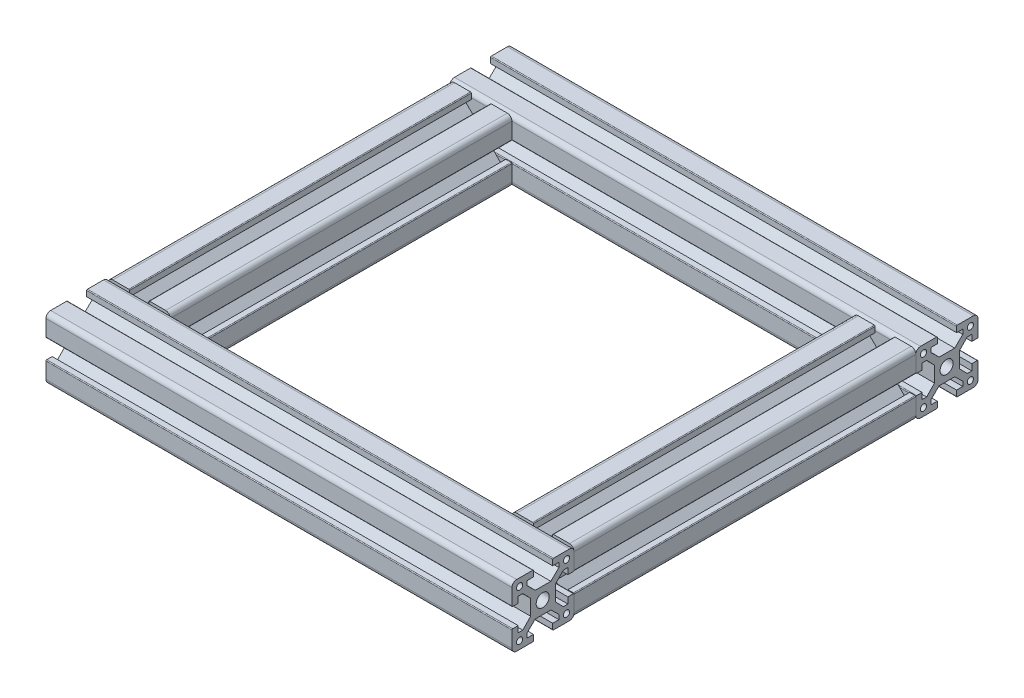
from build123d import *

# Parameters (mm, degrees)
SKETCH11_R                = 1
SKETCH11_R_2              = 2.1
XA_XA_2020T_1_DEPTH       = 140.110875788
XA_XA_2020T_1_DEPTH_BACK  = 9.889124212
SKETCH11_ON_SEGMENT_2_R   = 1
SKETCH11_ON_SEGMENT_2_R_2 = 2.1
XA_XA_2020T_1_2_DEPTH     = 150
SKETCH11_ON_SEGMENT_3_R   = 1
SKETCH11_ON_SEGMENT_3_R_2 = 2.1
XA_XA_2020T_1_3_DEPTH     = 132
SKETCH11_ON_SEGMENT_4_R   = 1
SKETCH11_ON_SEGMENT_4_R_2 = 2.1
XA_XA_2020T_1_4_DEPTH     = 132


with BuildPart() as part:
    # Sketch11 → Xa XA-2020T(1) (new, two sides)
    with BuildSketch(Plane(origin=(-46.28, 0, -40.646666667), x_dir=(0, 0, -1), z_dir=(1, 0, 0))) as xa_xa_2020t_1_sk:
        with BuildLine():
            Line((-9.889124212, 8.439448346), (-9.889124212, 3.289448346))
            ThreePointArc((-9.889124212, 3.289448346), (-9.815900907, 3.112671651), (-9.639124212, 3.039448346))
            Line((-9.639124212, 3.039448346), (-7.889124212, 3.039448346))
            Line((-7.889124212, 3.039448346), (-7.889124212, 5.039448346))
            Line((-7.889124212, 5.039448346), (-6.41690199, 5.039448346))
            Line((-6.41690199, 5.039448346), (-3.889124212, 2.439448346))
            Line((-3.889124212, 2.439448346), (-3.889124212, -2.560551654))
            Line((-3.889124212, -2.560551654), (-6.41690199, -5.160551654))
            Line((-6.41690199, -5.160551654), (-7.889124212, -5.160551654))
            Line((-7.889124212, -5.160551654), (-7.889124212, -3.160551654))
            Line((-7.889124212, -3.160551654), (-9.639124212, -3.160551654))
            ThreePointArc((-9.639124212, -3.160551654), (-9.815900907, -3.233774958), (-9.889124212, -3.410551654))
            Line((-9.889124212, -3.410551654), (-9.889124212, -8.560551654))
            ThreePointArc((-9.889124212, -8.560551654), (-9.449784384, -9.621211825), (-8.389124212, -10.060551654))
            Line((-8.389124212, -10.060551654), (-3.239124212, -10.060551654))
            ThreePointArc((-3.239124212, -10.060551654), (-3.062347516, -9.987328349), (-2.989124212, -9.810551654))
            Line((-2.989124212, -9.810551654), (-2.989124212, -8.060551654))
            Line((-2.989124212, -8.060551654), (-4.989124212, -8.060551654))
            Line((-4.989124212, -8.060551654), (-4.989124212, -6.588329431))
            Line((-4.989124212, -6.588329431), (-2.389124212, -4.060551654))
            Line((-2.389124212, -4.060551654), (2.610875788, -4.060551654))
            Line((2.610875788, -4.060551654), (5.210875788, -6.588329431))
            Line((5.210875788, -6.588329431), (5.210875788, -8.060551654))
            Line((5.210875788, -8.060551654), (3.210875788, -8.060551654))
            Line((3.210875788, -8.060551654), (3.210875788, -9.810551654))
            ThreePointArc((3.210875788, -9.810551654), (3.284099093, -9.987328349), (3.460875788, -10.060551654))
            Line((3.460875788, -10.060551654), (8.610875788, -10.060551654))
            ThreePointArc((8.610875788, -10.060551654), (9.67153596, -9.621211825), (10.110875788, -8.560551654))
            Line((10.110875788, -8.560551654), (10.110875788, -3.410551654))
            ThreePointArc((10.110875788, -3.410551654), (10.037652484, -3.233774958), (9.860875788, -3.160551654))
            Line((9.860875788, -3.160551654), (8.110875788, -3.160551654))
            Line((8.110875788, -3.160551654), (8.110875788, -5.160551654))
            Line((8.110875788, -5.160551654), (6.638653566, -5.160551654))
            Line((6.638653566, -5.160551654), (4.110875788, -2.560551654))
            Line((4.110875788, -2.560551654), (4.110875788, 2.439448346))
            Line((4.110875788, 2.439448346), (6.638653566, 5.039448346))
            Line((6.638653566, 5.039448346), (8.110875788, 5.039448346))
            Line((8.110875788, 5.039448346), (8.110875788, 3.039448346))
            Line((8.110875788, 3.039448346), (9.860875788, 3.039448346))
            ThreePointArc((9.860875788, 3.039448346), (10.037652484, 3.112671651), (10.110875788, 3.289448346))
            Line((10.110875788, 3.289448346), (10.110875788, 8.439448346))
            ThreePointArc((10.110875788, 8.439448346), (9.67153596, 9.500108518), (8.610875788, 9.939448346))
            Line((8.610875788, 9.939448346), (3.460875788, 9.939448346))
            ThreePointArc((3.460875788, 9.939448346), (3.284099093, 9.866225042), (3.210875788, 9.689448346))
            Line((3.210875788, 9.689448346), (3.210875788, 7.939448346))
            Line((3.210875788, 7.939448346), (5.210875788, 7.939448346))
            Line((5.210875788, 7.939448346), (5.210875788, 6.467226124))
            Line((5.210875788, 6.467226124), (2.610875788, 3.939448346))
            Line((2.610875788, 3.939448346), (-2.389124212, 3.939448346))
            Line((-2.389124212, 3.939448346), (-4.989124212, 6.467226124))
            Line((-4.989124212, 6.467226124), (-4.989124212, 7.939448346))
            Line((-4.989124212, 7.939448346), (-2.989124212, 7.939448346))
            Line((-2.989124212, 7.939448346), (-2.989124212, 9.689448346))
            ThreePointArc((-2.989124212, 9.689448346), (-3.062347516, 9.866225042), (-3.239124212, 9.939448346))
            Line((-3.239124212, 9.939448346), (-8.389124212, 9.939448346))
            ThreePointArc((-8.389124212, 9.939448346), (-9.449784384, 9.500108518), (-9.889124212, 8.439448346))
        make_face()
        with Locations((-7.439124212, 7.489448346)):
            Circle(SKETCH11_R, mode=Mode.SUBTRACT)
        with Locations((7.660875788, 7.489448346)):
            Circle(SKETCH11_R, mode=Mode.SUBTRACT)
        with Locations((-7.439124212, -7.610551654)):
            Circle(SKETCH11_R, mode=Mode.SUBTRACT)
        with Locations((7.660875788, -7.610551654)):
            Circle(SKETCH11_R, mode=Mode.SUBTRACT)
        Circle(SKETCH11_R_2, mode=Mode.SUBTRACT)
    extrude(amount=XA_XA_2020T_1_DEPTH)
    extrude(xa_xa_2020t_1_sk.sketch, amount=-XA_XA_2020T_1_DEPTH_BACK)


with BuildPart() as body_2:
    # Sketch11 on segment 2 (carried to segment 2) → Xa XA-2020T_1 2 (new body)
    with BuildSketch(Plane(origin=(-56.169124212, 0, 89.353333333), x_dir=(0, 0, -1), z_dir=(1, 0, 0))):
        with BuildLine():
            Line((-9.889124212, 8.439448346), (-9.889124212, 3.289448346))
            ThreePointArc((-9.889124212, 3.289448346), (-9.815900907, 3.112671651), (-9.639124212, 3.039448346))
            Line((-9.639124212, 3.039448346), (-7.889124212, 3.039448346))
            Line((-7.889124212, 3.039448346), (-7.889124212, 5.039448346))
            Line((-7.889124212, 5.039448346), (-6.41690199, 5.039448346))
            Line((-6.41690199, 5.039448346), (-3.889124212, 2.439448346))
            Line((-3.889124212, 2.439448346), (-3.889124212, -2.560551654))
            Line((-3.889124212, -2.560551654), (-6.41690199, -5.160551654))
            Line((-6.41690199, -5.160551654), (-7.889124212, -5.160551654))
            Line((-7.889124212, -5.160551654), (-7.889124212, -3.160551654))
            Line((-7.889124212, -3.160551654), (-9.639124212, -3.160551654))
            ThreePointArc((-9.639124212, -3.160551654), (-9.815900907, -3.233774958), (-9.889124212, -3.410551654))
            Line((-9.889124212, -3.410551654), (-9.889124212, -8.560551654))
            ThreePointArc((-9.889124212, -8.560551654), (-9.449784384, -9.621211825), (-8.389124212, -10.060551654))
            Line((-8.389124212, -10.060551654), (-3.239124212, -10.060551654))
            ThreePointArc((-3.239124212, -10.060551654), (-3.062347516, -9.987328349), (-2.989124212, -9.810551654))
            Line((-2.989124212, -9.810551654), (-2.989124212, -8.060551654))
            Line((-2.989124212, -8.060551654), (-4.989124212, -8.060551654))
            Line((-4.989124212, -8.060551654), (-4.989124212, -6.588329431))
            Line((-4.989124212, -6.588329431), (-2.389124212, -4.060551654))
            Line((-2.389124212, -4.060551654), (2.610875788, -4.060551654))
            Line((2.610875788, -4.060551654), (5.210875788, -6.588329431))
            Line((5.210875788, -6.588329431), (5.210875788, -8.060551654))
            Line((5.210875788, -8.060551654), (3.210875788, -8.060551654))
            Line((3.210875788, -8.060551654), (3.210875788, -9.810551654))
            ThreePointArc((3.210875788, -9.810551654), (3.284099093, -9.987328349), (3.460875788, -10.060551654))
            Line((3.460875788, -10.060551654), (8.610875788, -10.060551654))
            ThreePointArc((8.610875788, -10.060551654), (9.67153596, -9.621211825), (10.110875788, -8.560551654))
            Line((10.110875788, -8.560551654), (10.110875788, -3.410551654))
            ThreePointArc((10.110875788, -3.410551654), (10.037652484, -3.233774958), (9.860875788, -3.160551654))
            Line((9.860875788, -3.160551654), (8.110875788, -3.160551654))
            Line((8.110875788, -3.160551654), (8.110875788, -5.160551654))
            Line((8.110875788, -5.160551654), (6.638653566, -5.160551654))
            Line((6.638653566, -5.160551654), (4.110875788, -2.560551654))
            Line((4.110875788, -2.560551654), (4.110875788, 2.439448346))
            Line((4.110875788, 2.439448346), (6.638653566, 5.039448346))
            Line((6.638653566, 5.039448346), (8.110875788, 5.039448346))
            Line((8.110875788, 5.039448346), (8.110875788, 3.039448346))
            Line((8.110875788, 3.039448346), (9.860875788, 3.039448346))
            ThreePointArc((9.860875788, 3.039448346), (10.037652484, 3.112671651), (10.110875788, 3.289448346))
            Line((10.110875788, 3.289448346), (10.110875788, 8.439448346))
            ThreePointArc((10.110875788, 8.439448346), (9.67153596, 9.500108518), (8.610875788, 9.939448346))
            Line((8.610875788, 9.939448346), (3.460875788, 9.939448346))
            ThreePointArc((3.460875788, 9.939448346), (3.284099093, 9.866225042), (3.210875788, 9.689448346))
            Line((3.210875788, 9.689448346), (3.210875788, 7.939448346))
            Line((3.210875788, 7.939448346), (5.210875788, 7.939448346))
            Line((5.210875788, 7.939448346), (5.210875788, 6.467226124))
            Line((5.210875788, 6.467226124), (2.610875788, 3.939448346))
            Line((2.610875788, 3.939448346), (-2.389124212, 3.939448346))
            Line((-2.389124212, 3.939448346), (-4.989124212, 6.467226124))
            Line((-4.989124212, 6.467226124), (-4.989124212, 7.939448346))
            Line((-4.989124212, 7.939448346), (-2.989124212, 7.939448346))
            Line((-2.989124212, 7.939448346), (-2.989124212, 9.689448346))
            ThreePointArc((-2.989124212, 9.689448346), (-3.062347516, 9.866225042), (-3.239124212, 9.939448346))
            Line((-3.239124212, 9.939448346), (-8.389124212, 9.939448346))
            ThreePointArc((-8.389124212, 9.939448346), (-9.449784384, 9.500108518), (-9.889124212, 8.439448346))
        make_face()
        with Locations((-7.439124212, 7.489448346)):
            Circle(SKETCH11_ON_SEGMENT_2_R, mode=Mode.SUBTRACT)
        with Locations((7.660875788, 7.489448346)):
            Circle(SKETCH11_ON_SEGMENT_2_R, mode=Mode.SUBTRACT)
        with Locations((-7.439124212, -7.610551654)):
            Circle(SKETCH11_ON_SEGMENT_2_R, mode=Mode.SUBTRACT)
        with Locations((7.660875788, -7.610551654)):
            Circle(SKETCH11_ON_SEGMENT_2_R, mode=Mode.SUBTRACT)
        Circle(SKETCH11_ON_SEGMENT_2_R_2, mode=Mode.SUBTRACT)
    extrude(amount=XA_XA_2020T_1_2_DEPTH)


with BuildPart() as body_3:
    # Sketch11 on segment 3 (carried to segment 3) → Xa XA-2020T_1 3 (new body)
    with BuildSketch(Plane(origin=(-46.28, 0, -41.646666667), x_dir=(1, 0, 0), z_dir=(0, 0, 1))):
        with BuildLine():
            Line((-9.889124212, 8.439448346), (-9.889124212, 3.289448346))
            ThreePointArc((-9.889124212, 3.289448346), (-9.815900907, 3.112671651), (-9.639124212, 3.039448346))
            Line((-9.639124212, 3.039448346), (-7.889124212, 3.039448346))
            Line((-7.889124212, 3.039448346), (-7.889124212, 5.039448346))
            Line((-7.889124212, 5.039448346), (-6.41690199, 5.039448346))
            Line((-6.41690199, 5.039448346), (-3.889124212, 2.439448346))
            Line((-3.889124212, 2.439448346), (-3.889124212, -2.560551654))
            Line((-3.889124212, -2.560551654), (-6.41690199, -5.160551654))
            Line((-6.41690199, -5.160551654), (-7.889124212, -5.160551654))
            Line((-7.889124212, -5.160551654), (-7.889124212, -3.160551654))
            Line((-7.889124212, -3.160551654), (-9.639124212, -3.160551654))
            ThreePointArc((-9.639124212, -3.160551654), (-9.815900907, -3.233774958), (-9.889124212, -3.410551654))
            Line((-9.889124212, -3.410551654), (-9.889124212, -8.560551654))
            ThreePointArc((-9.889124212, -8.560551654), (-9.449784384, -9.621211825), (-8.389124212, -10.060551654))
            Line((-8.389124212, -10.060551654), (-3.239124212, -10.060551654))
            ThreePointArc((-3.239124212, -10.060551654), (-3.062347516, -9.987328349), (-2.989124212, -9.810551654))
            Line((-2.989124212, -9.810551654), (-2.989124212, -8.060551654))
            Line((-2.989124212, -8.060551654), (-4.989124212, -8.060551654))
            Line((-4.989124212, -8.060551654), (-4.989124212, -6.588329431))
            Line((-4.989124212, -6.588329431), (-2.389124212, -4.060551654))
            Line((-2.389124212, -4.060551654), (2.610875788, -4.060551654))
            Line((2.610875788, -4.060551654), (5.210875788, -6.588329431))
            Line((5.210875788, -6.588329431), (5.210875788, -8.060551654))
            Line((5.210875788, -8.060551654), (3.210875788, -8.060551654))
            Line((3.210875788, -8.060551654), (3.210875788, -9.810551654))
            ThreePointArc((3.210875788, -9.810551654), (3.284099093, -9.987328349), (3.460875788, -10.060551654))
            Line((3.460875788, -10.060551654), (8.610875788, -10.060551654))
            ThreePointArc((8.610875788, -10.060551654), (9.67153596, -9.621211825), (10.110875788, -8.560551654))
            Line((10.110875788, -8.560551654), (10.110875788, -3.410551654))
            ThreePointArc((10.110875788, -3.410551654), (10.037652484, -3.233774958), (9.860875788, -3.160551654))
            Line((9.860875788, -3.160551654), (8.110875788, -3.160551654))
            Line((8.110875788, -3.160551654), (8.110875788, -5.160551654))
            Line((8.110875788, -5.160551654), (6.638653566, -5.160551654))
            Line((6.638653566, -5.160551654), (4.110875788, -2.560551654))
            Line((4.110875788, -2.560551654), (4.110875788, 2.439448346))
            Line((4.110875788, 2.439448346), (6.638653566, 5.039448346))
            Line((6.638653566, 5.039448346), (8.110875788, 5.039448346))
            Line((8.110875788, 5.039448346), (8.110875788, 3.039448346))
            Line((8.110875788, 3.039448346), (9.860875788, 3.039448346))
            ThreePointArc((9.860875788, 3.039448346), (10.037652484, 3.112671651), (10.110875788, 3.289448346))
            Line((10.110875788, 3.289448346), (10.110875788, 8.439448346))
            ThreePointArc((10.110875788, 8.439448346), (9.67153596, 9.500108518), (8.610875788, 9.939448346))
            Line((8.610875788, 9.939448346), (3.460875788, 9.939448346))
            ThreePointArc((3.460875788, 9.939448346), (3.284099093, 9.866225042), (3.210875788, 9.689448346))
            Line((3.210875788, 9.689448346), (3.210875788, 7.939448346))
            Line((3.210875788, 7.939448346), (5.210875788, 7.939448346))
            Line((5.210875788, 7.939448346), (5.210875788, 6.467226124))
            Line((5.210875788, 6.467226124), (2.610875788, 3.939448346))
            Line((2.610875788, 3.939448346), (-2.389124212, 3.939448346))
            Line((-2.389124212, 3.939448346), (-4.989124212, 6.467226124))
            Line((-4.989124212, 6.467226124), (-4.989124212, 7.939448346))
            Line((-4.989124212, 7.939448346), (-2.989124212, 7.939448346))
            Line((-2.989124212, 7.939448346), (-2.989124212, 9.689448346))
            ThreePointArc((-2.989124212, 9.689448346), (-3.062347516, 9.866225042), (-3.239124212, 9.939448346))
            Line((-3.239124212, 9.939448346), (-8.389124212, 9.939448346))
            ThreePointArc((-8.389124212, 9.939448346), (-9.449784384, 9.500108518), (-9.889124212, 8.439448346))
        make_face()
        with Locations((-7.439124212, 7.489448346)):
            Circle(SKETCH11_ON_SEGMENT_3_R, mode=Mode.SUBTRACT)
        with Locations((7.660875788, 7.489448346)):
            Circle(SKETCH11_ON_SEGMENT_3_R, mode=Mode.SUBTRACT)
        with Locations((-7.439124212, -7.610551654)):
            Circle(SKETCH11_ON_SEGMENT_3_R, mode=Mode.SUBTRACT)
        with Locations((7.660875788, -7.610551654)):
            Circle(SKETCH11_ON_SEGMENT_3_R, mode=Mode.SUBTRACT)
        Circle(SKETCH11_ON_SEGMENT_3_R_2, mode=Mode.SUBTRACT)
    extrude(amount=XA_XA_2020T_1_3_DEPTH)

    # Xa XA-2020T_1 3 end butt 1
    split(bisect_by=Plane(origin=(-46.28, 0, -30.757542455), x_dir=(0, -1, 0), z_dir=(0, 0, 1)), keep=Keep.TOP)

    # Xa XA-2020T_1 3 end butt 2
    split(bisect_by=Plane(origin=(-46.28, 0, 79.242457545), x_dir=(0, 1, 0), z_dir=(0, 0, -1)), keep=Keep.TOP)


with BuildPart() as body_4:
    # Sketch11 on segment 4 (carried to segment 4) → Xa XA-2020T_1 4 (new body)
    with BuildSketch(Plane(origin=(83.72, 0, -41.646666667), x_dir=(1, 0, 0), z_dir=(0, 0, 1))):
        with BuildLine():
            Line((-9.889124212, 8.439448346), (-9.889124212, 3.289448346))
            ThreePointArc((-9.889124212, 3.289448346), (-9.815900907, 3.112671651), (-9.639124212, 3.039448346))
            Line((-9.639124212, 3.039448346), (-7.889124212, 3.039448346))
            Line((-7.889124212, 3.039448346), (-7.889124212, 5.039448346))
            Line((-7.889124212, 5.039448346), (-6.41690199, 5.039448346))
            Line((-6.41690199, 5.039448346), (-3.889124212, 2.439448346))
            Line((-3.889124212, 2.439448346), (-3.889124212, -2.560551654))
            Line((-3.889124212, -2.560551654), (-6.41690199, -5.160551654))
            Line((-6.41690199, -5.160551654), (-7.889124212, -5.160551654))
            Line((-7.889124212, -5.160551654), (-7.889124212, -3.160551654))
            Line((-7.889124212, -3.160551654), (-9.639124212, -3.160551654))
            ThreePointArc((-9.639124212, -3.160551654), (-9.815900907, -3.233774958), (-9.889124212, -3.410551654))
            Line((-9.889124212, -3.410551654), (-9.889124212, -8.560551654))
            ThreePointArc((-9.889124212, -8.560551654), (-9.449784384, -9.621211825), (-8.389124212, -10.060551654))
            Line((-8.389124212, -10.060551654), (-3.239124212, -10.060551654))
            ThreePointArc((-3.239124212, -10.060551654), (-3.062347516, -9.987328349), (-2.989124212, -9.810551654))
            Line((-2.989124212, -9.810551654), (-2.989124212, -8.060551654))
            Line((-2.989124212, -8.060551654), (-4.989124212, -8.060551654))
            Line((-4.989124212, -8.060551654), (-4.989124212, -6.588329431))
            Line((-4.989124212, -6.588329431), (-2.389124212, -4.060551654))
            Line((-2.389124212, -4.060551654), (2.610875788, -4.060551654))
            Line((2.610875788, -4.060551654), (5.210875788, -6.588329431))
            Line((5.210875788, -6.588329431), (5.210875788, -8.060551654))
            Line((5.210875788, -8.060551654), (3.210875788, -8.060551654))
            Line((3.210875788, -8.060551654), (3.210875788, -9.810551654))
            ThreePointArc((3.210875788, -9.810551654), (3.284099093, -9.987328349), (3.460875788, -10.060551654))
            Line((3.460875788, -10.060551654), (8.610875788, -10.060551654))
            ThreePointArc((8.610875788, -10.060551654), (9.67153596, -9.621211825), (10.110875788, -8.560551654))
            Line((10.110875788, -8.560551654), (10.110875788, -3.410551654))
            ThreePointArc((10.110875788, -3.410551654), (10.037652484, -3.233774958), (9.860875788, -3.160551654))
            Line((9.860875788, -3.160551654), (8.110875788, -3.160551654))
            Line((8.110875788, -3.160551654), (8.110875788, -5.160551654))
            Line((8.110875788, -5.160551654), (6.638653566, -5.160551654))
            Line((6.638653566, -5.160551654), (4.110875788, -2.560551654))
            Line((4.110875788, -2.560551654), (4.110875788, 2.439448346))
            Line((4.110875788, 2.439448346), (6.638653566, 5.039448346))
            Line((6.638653566, 5.039448346), (8.110875788, 5.039448346))
            Line((8.110875788, 5.039448346), (8.110875788, 3.039448346))
            Line((8.110875788, 3.039448346), (9.860875788, 3.039448346))
            ThreePointArc((9.860875788, 3.039448346), (10.037652484, 3.112671651), (10.110875788, 3.289448346))
            Line((10.110875788, 3.289448346), (10.110875788, 8.439448346))
            ThreePointArc((10.110875788, 8.439448346), (9.67153596, 9.500108518), (8.610875788, 9.939448346))
            Line((8.610875788, 9.939448346), (3.460875788, 9.939448346))
            ThreePointArc((3.460875788, 9.939448346), (3.284099093, 9.866225042), (3.210875788, 9.689448346))
            Line((3.210875788, 9.689448346), (3.210875788, 7.939448346))
            Line((3.210875788, 7.939448346), (5.210875788, 7.939448346))
            Line((5.210875788, 7.939448346), (5.210875788, 6.467226124))
            Line((5.210875788, 6.467226124), (2.610875788, 3.939448346))
            Line((2.610875788, 3.939448346), (-2.389124212, 3.939448346))
            Line((-2.389124212, 3.939448346), (-4.989124212, 6.467226124))
            Line((-4.989124212, 6.467226124), (-4.989124212, 7.939448346))
            Line((-4.989124212, 7.939448346), (-2.989124212, 7.939448346))
            Line((-2.989124212, 7.939448346), (-2.989124212, 9.689448346))
            ThreePointArc((-2.989124212, 9.689448346), (-3.062347516, 9.866225042), (-3.239124212, 9.939448346))
            Line((-3.239124212, 9.939448346), (-8.389124212, 9.939448346))
            ThreePointArc((-8.389124212, 9.939448346), (-9.449784384, 9.500108518), (-9.889124212, 8.439448346))
        make_face()
        with Locations((-7.439124212, 7.489448346)):
            Circle(SKETCH11_ON_SEGMENT_4_R, mode=Mode.SUBTRACT)
        with Locations((7.660875788, 7.489448346)):
            Circle(SKETCH11_ON_SEGMENT_4_R, mode=Mode.SUBTRACT)
        with Locations((-7.439124212, -7.610551654)):
            Circle(SKETCH11_ON_SEGMENT_4_R, mode=Mode.SUBTRACT)
        with Locations((7.660875788, -7.610551654)):
            Circle(SKETCH11_ON_SEGMENT_4_R, mode=Mode.SUBTRACT)
        Circle(SKETCH11_ON_SEGMENT_4_R_2, mode=Mode.SUBTRACT)
    extrude(amount=XA_XA_2020T_1_4_DEPTH)

    # Xa XA-2020T_1 4 end butt 1
    split(bisect_by=Plane(origin=(83.72, 0, -30.757542455), x_dir=(0, -1, 0), z_dir=(0, 0, 1)), keep=Keep.TOP)

    # Xa XA-2020T_1 4 end butt 2
    split(bisect_by=Plane(origin=(83.72, 0, 79.242457545), x_dir=(0, 1, 0), z_dir=(0, 0, -1)), keep=Keep.TOP)


solid = Compound([part.part, body_2.part, body_3.part, body_4.part])
